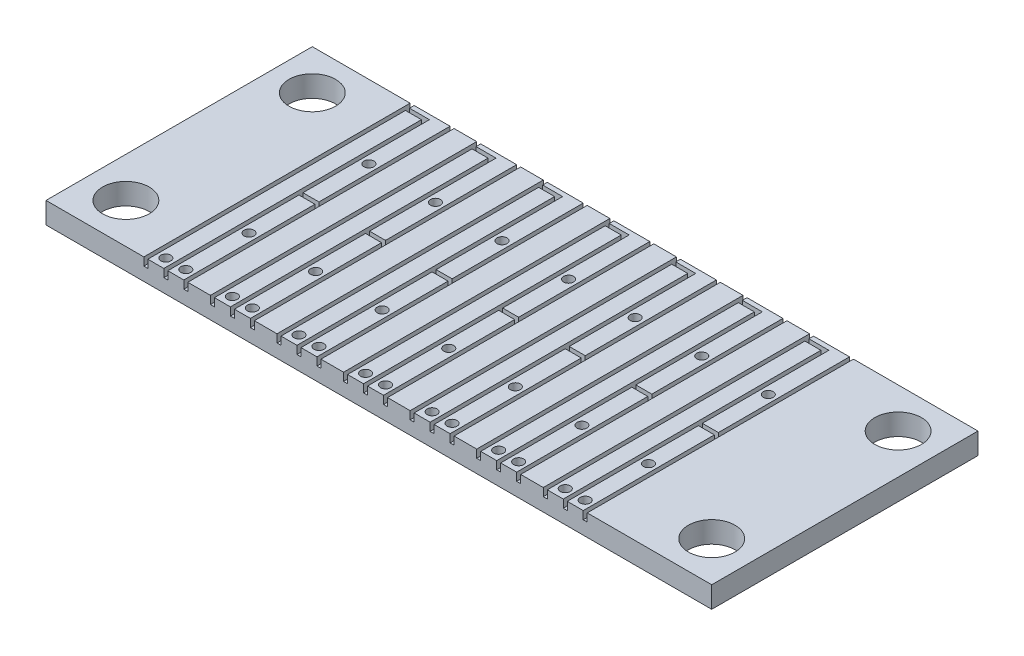
from build123d import *

# Parameters (mm, degrees)
SKETCH1_W           = 50
SKETCH1_H           = 20
SKETCH1_R           = 1.75
BOSS_EXTRUDE1_DEPTH = 1.6
SKETCH3_R           = 0.375
CUT_EXTRUDE1_DEPTH  = 2.6
SKETCH2_W           = 0.3
SKETCH2_H           = 20
SKETCH2_W_2         = 1.5
SKETCH2_H_2         = 0.3
CUT_EXTRUDE2_DEPTH  = 0.6
LPATTERN1_COUNT     = 7
LPATTERN1_PITCH     = 5
LPATTERN2_COUNT     = 7
LPATTERN2_PITCH     = 5


with BuildPart() as part:
    # Sketch1 → Boss-Extrude1 (new body)
    with BuildSketch(Plane(origin=(0, 0, 0), x_dir=(1, 0, 0), z_dir=(0, 1, 0))):
        with Locations((25, 10)):
            Rectangle(SKETCH1_W, SKETCH1_H)
        with Locations((3, 17)):
            Circle(SKETCH1_R, mode=Mode.SUBTRACT)
        with Locations((47, 3)):
            Circle(SKETCH1_R, mode=Mode.SUBTRACT)
        with Locations((3, 3)):
            Circle(SKETCH1_R, mode=Mode.SUBTRACT)
        with Locations((47, 17)):
            Circle(SKETCH1_R, mode=Mode.SUBTRACT)
    extrude(amount=BOSS_EXTRUDE1_DEPTH)

    # Sketch3 → Cut-Extrude1 (cut, through all)
    with BuildSketch(Plane(origin=(0, 1.6, 0), x_dir=(1, 0, 0), z_dir=(0, 1, 0))):
        with Locations((8.25, 0.75)):
            Circle(SKETCH3_R)
        with Locations((9.75, 0.75)):
            Circle(SKETCH3_R)
        with Locations((9.75, 5.5)):
            Circle(SKETCH3_R)
        with Locations((9.75, 14.5)):
            Circle(SKETCH3_R)
    cut_extrude1 = extrude(amount=-CUT_EXTRUDE1_DEPTH, mode=Mode.SUBTRACT)

    # Sketch2 → Cut-Extrude2 (cut)
    with BuildSketch(Plane(origin=(0, 1.6, 0), x_dir=(1, 0, 0), z_dir=(0, 1, 0))):
        Polygon((9.15, 0), (9.15, 19.65), (7.5, 19.65), (7.5, 19.35), (8.85, 19.35), (8.85, 0), align=None)
        with Locations((7.5, 10)):
            Rectangle(SKETCH2_W, SKETCH2_H)
        with Locations((10.5, 10)):
            Rectangle(SKETCH2_W, SKETCH2_H)
        with Locations((9.75, 10)):
            Rectangle(SKETCH2_W_2, SKETCH2_H_2)
    cut_extrude2 = extrude(amount=-CUT_EXTRUDE2_DEPTH, mode=Mode.SUBTRACT)

    # LPattern1: Cut-Extrude1 ×7
    with Locations(*[(i * LPATTERN1_PITCH, 0, 0) for i in range(1, LPATTERN1_COUNT)]):
        add(cut_extrude1, mode=Mode.SUBTRACT)

    # LPattern2: Cut-Extrude2 ×7
    with Locations(*[(i * LPATTERN2_PITCH, 0, 0) for i in range(1, LPATTERN2_COUNT)]):
        add(cut_extrude2, mode=Mode.SUBTRACT)


solid = part.part
